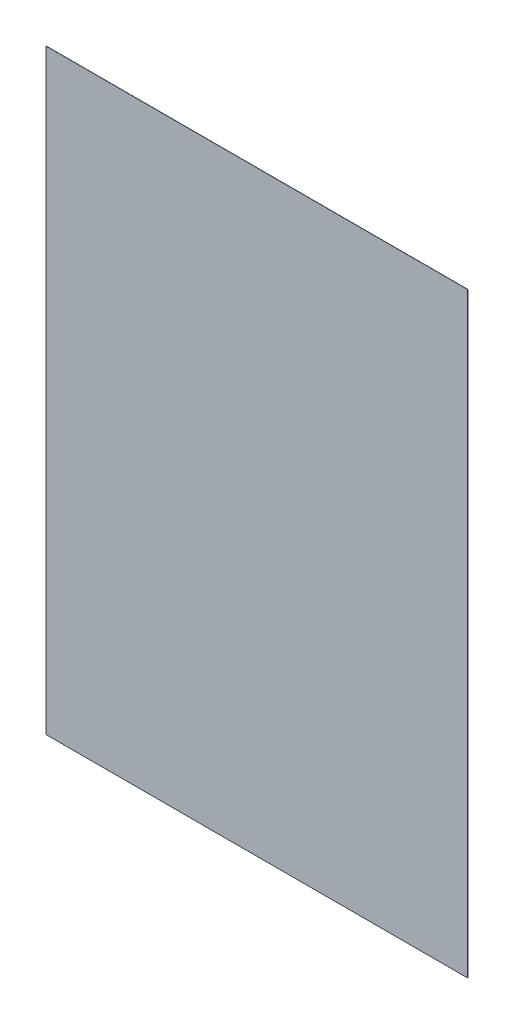
from build123d import *

# Parameters (mm, degrees)
SKETCH1_W           = 210
SKETCH1_H           = 297
BOSS_EXTRUDE1_DEPTH = 0.1


with BuildPart() as part:
    # Sketch1 → Boss-Extrude1 (new body)
    with BuildSketch(Plane.XY):
        with Locations((105, 148.5)):
            Rectangle(SKETCH1_W, SKETCH1_H)
    extrude(amount=BOSS_EXTRUDE1_DEPTH)


solid = part.part
